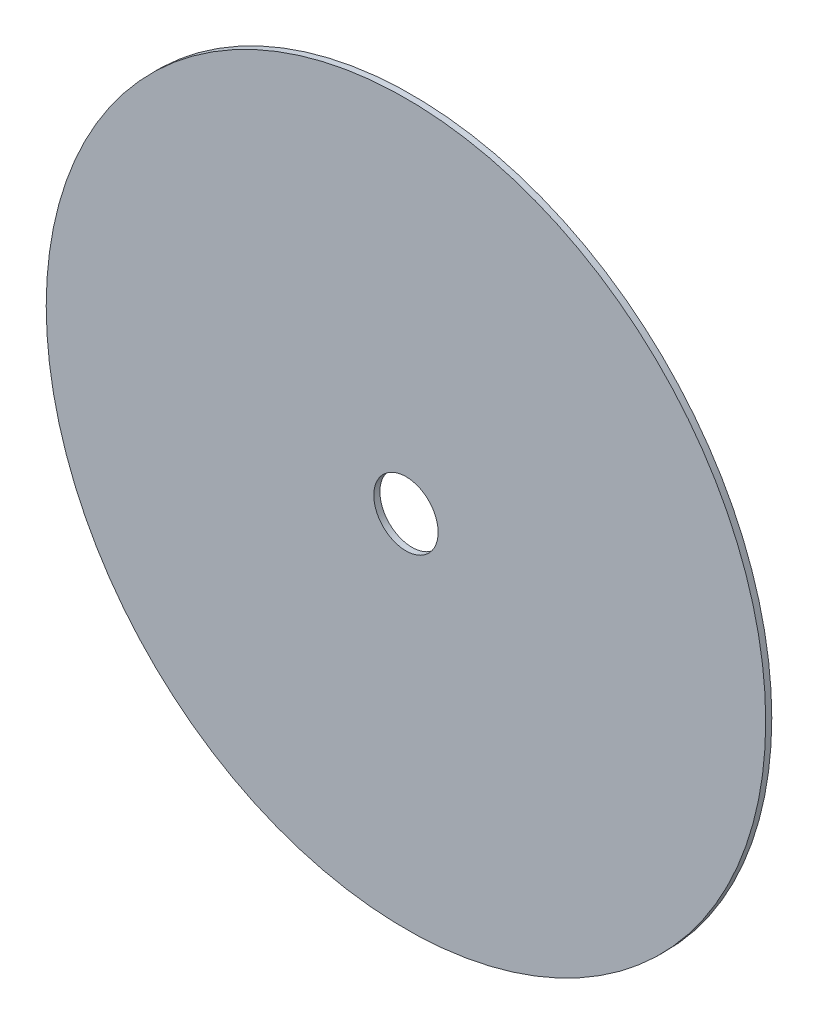
from build123d import *

# Parameters (mm, degrees)
SKETCH1_R           = 177.8
SKETCH1_R_2         = 15.9
BOSS_EXTRUDE1_DEPTH = 3


with BuildPart() as part:
    # Sketch1 → Boss-Extrude1 (new body)
    with BuildSketch(Plane.XY):
        Circle(SKETCH1_R)
        Circle(SKETCH1_R_2, mode=Mode.SUBTRACT)
    extrude(amount=BOSS_EXTRUDE1_DEPTH)


solid = part.part
